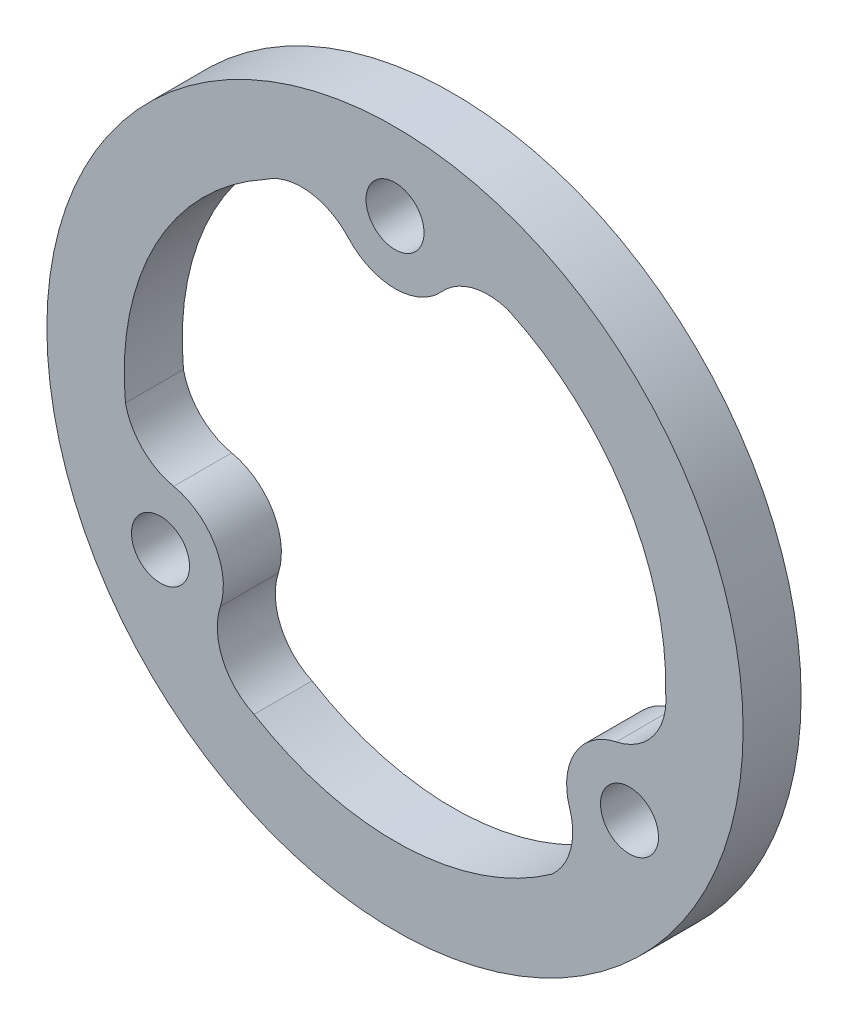
from build123d import *

# Parameters (mm, degrees)
ESQUISSE1_R        = 18
ESQUISSE1_R_2      = 1.5
BOSS_EXTRU_2_DEPTH = 3


with BuildPart() as part:
    # Esquisse1 → Boss.-Extru.2 (new body)
    with BuildSketch(Plane.XY):
        Circle(ESQUISSE1_R)
        with Locations((0, 14)):
            Circle(ESQUISSE1_R_2, mode=Mode.SUBTRACT)
        with Locations((12.124355653, -7)):
            Circle(ESQUISSE1_R_2, mode=Mode.SUBTRACT)
        with Locations((-12.124355653, -7)):
            Circle(ESQUISSE1_R_2, mode=Mode.SUBTRACT)
        with BuildLine():
            ThreePointArc((-2.411034891, 11.820685714), (0, 10.75), (2.411034891, 11.820685714))
            ThreePointArc((2.411034891, 11.820685714), (3.975330286, 12.779130538), (5.80943088, 12.737759334))
            ThreePointArc((5.80943088, 12.737759334), (11.865562564, 7.430237213), (13.995977593, -0.335575935))
            ThreePointArc((13.995977593, -0.335575935), (13.382779595, -2.564868949), (11.442531564, -3.822325392))
            ThreePointArc((11.442531564, -3.822325392), (9.309773091, -5.375), (9.031496673, -7.998360322))
            ThreePointArc((9.031496673, -7.998360322), (9.079386541, -9.832302285), (8.126507731, -11.399994391))
            ThreePointArc((8.126507731, -11.399994391), (0.5019929, -13.990997217), (-7.288606081, -11.953084179))
            ThreePointArc((-7.288606081, -11.953084179), (-8.912631465, -10.307392628), (-9.031496673, -7.998360322))
            ThreePointArc((-9.031496673, -7.998360322), (-9.309773091, -5.375), (-11.442531564, -3.822325392))
            ThreePointArc((-11.442531564, -3.822325392), (-13.054716827, -2.946828253), (-13.935938611, -1.337764944))
            ThreePointArc((-13.935938611, -1.337764944), (-12.367555464, 6.560760004), (-6.707371512, 12.288660114))
            ThreePointArc((-6.707371512, 12.288660114), (-4.47014813, 12.872261577), (-2.411034891, 11.820685714))
        make_face(mode=Mode.SUBTRACT)
    extrude(amount=BOSS_EXTRU_2_DEPTH)


solid = part.part
